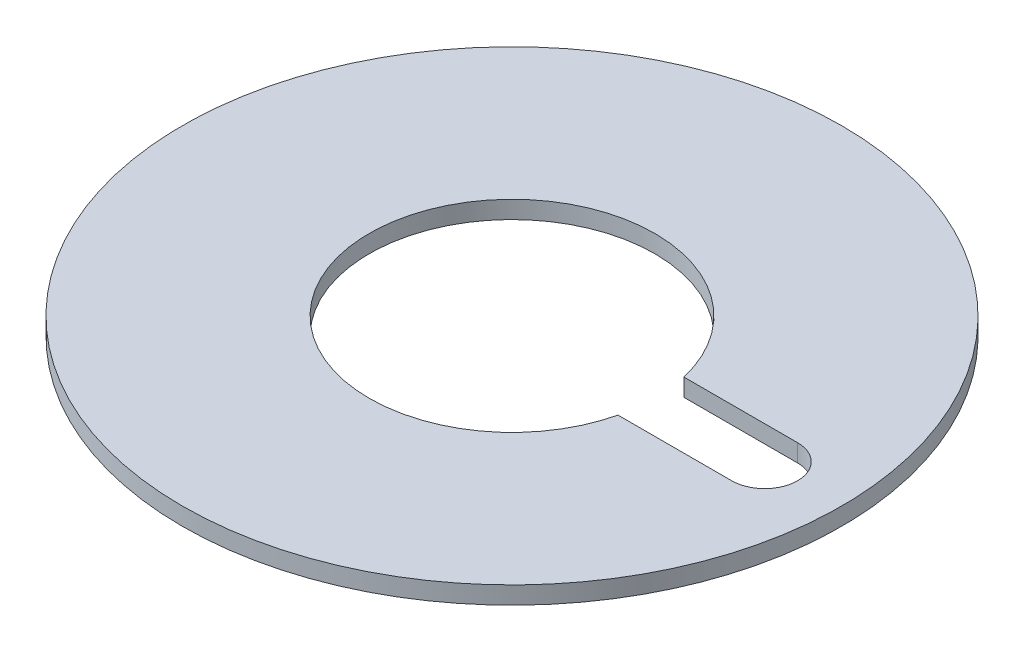
from build123d import *

# Parameters (mm, degrees)
SKETCH1_R           = 15
BOSS_EXTRUDE1_DEPTH = 0.8
CUT_EXTRUDE1_DEPTH  = 1.8


with BuildPart() as part:
    # Sketch1 → Boss-Extrude1 (new body)
    with BuildSketch(Plane(origin=(0, 0, 0), x_dir=(1, 0, 0), z_dir=(0, 1, 0))):
        Circle(SKETCH1_R)
    extrude(amount=BOSS_EXTRUDE1_DEPTH)

    # Sketch3 → Cut-Extrude1 (cut, through all)
    with BuildSketch(Plane(origin=(0, 0.8, 0), x_dir=(1, 0, 0), z_dir=(0, 1, 0))):
        with BuildLine():
            Line((6.32455532, -1.5), (11.5, -1.5))
            ThreePointArc((11.5, -1.5), (13, 0), (11.5, 1.5))
            Line((11.5, 1.5), (6.32455532, 1.5))
            ThreePointArc((6.32455532, 1.5), (-6.5, 0), (6.32455532, -1.5))
        make_face()
    extrude(amount=-CUT_EXTRUDE1_DEPTH, mode=Mode.SUBTRACT)


solid = part.part
